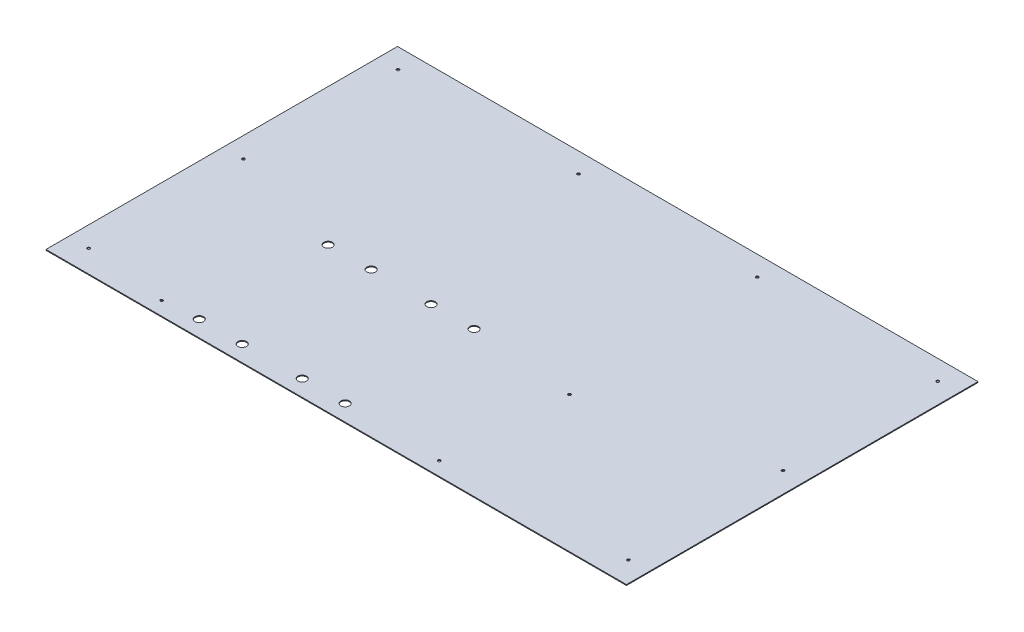
from build123d import *

# Parameters (mm, degrees)
CROQUIS1_W              = 675.4
CROQUIS1_H              = 409
SALIENTE_EXTRUIR1_DEPTH = 1
CORTAR_EXTRUIR1_REACH   = 3
CROQUIS2_R              = 1.6
CORTAR_EXTRUIR2_REACH   = 3
CROQUIS3_R              = 5
CORTAR_EXTRUIR3_REACH   = 3
CROQUIS4_R              = 1.6


with BuildPart() as part:
    # Croquis1 → Saliente-Extruir1 (new body)
    with BuildSketch(Plane(origin=(0, 0, 0), x_dir=(1, 0, 0), z_dir=(0, 1, 0))):
        Rectangle(CROQUIS1_W, CROQUIS1_H)
    extrude(amount=SALIENTE_EXTRUIR1_DEPTH)

    # Croquis2 → Cortar-Extruir1 (cut, up to next)
    with BuildSketch(Plane.XZ, mode=Mode.PRIVATE) as cortar_extruir1_sk1:
        with Locations((-314, 178.6)):
            Circle(CROQUIS2_R)
    cortar_extruir1_tool1 = extrude(cortar_extruir1_sk1.sketch, amount=-CORTAR_EXTRUIR1_REACH, mode=Mode.PRIVATE) & part.part
    add(cortar_extruir1_tool1.solids().sort_by_distance((-314, 0, 178.6))[0], mode=Mode.SUBTRACT)
    # Croquis2 → Cortar-Extruir1 (cut, up to next)
    with BuildSketch(Plane.XZ, mode=Mode.PRIVATE) as cortar_extruir1_sk2:
        with Locations((-314, -181.4)):
            Circle(CROQUIS2_R)
    cortar_extruir1_tool2 = extrude(cortar_extruir1_sk2.sketch, amount=-CORTAR_EXTRUIR1_REACH, mode=Mode.PRIVATE) & part.part
    add(cortar_extruir1_tool2.solids().sort_by_distance((-314, 0, -181.4))[0], mode=Mode.SUBTRACT)
    # Croquis2 → Cortar-Extruir1 (cut, up to next)
    with BuildSketch(Plane.XZ, mode=Mode.PRIVATE) as cortar_extruir1_sk3:
        with Locations((314, -181.4)):
            Circle(CROQUIS2_R)
    cortar_extruir1_tool3 = extrude(cortar_extruir1_sk3.sketch, amount=-CORTAR_EXTRUIR1_REACH, mode=Mode.PRIVATE) & part.part
    add(cortar_extruir1_tool3.solids().sort_by_distance((314, 0, -181.4))[0], mode=Mode.SUBTRACT)
    # Croquis2 → Cortar-Extruir1 (cut, up to next)
    with BuildSketch(Plane.XZ, mode=Mode.PRIVATE) as cortar_extruir1_sk4:
        with Locations((314, 178.6)):
            Circle(CROQUIS2_R)
    cortar_extruir1_tool4 = extrude(cortar_extruir1_sk4.sketch, amount=-CORTAR_EXTRUIR1_REACH, mode=Mode.PRIVATE) & part.part
    add(cortar_extruir1_tool4.solids().sort_by_distance((314, 0, 178.6))[0], mode=Mode.SUBTRACT)
    # Croquis2 → Cortar-Extruir1 (cut, up to next)
    with BuildSketch(Plane.XZ, mode=Mode.PRIVATE) as cortar_extruir1_sk5:
        with Locations((113, 46.25)):
            Circle(CROQUIS2_R)
    cortar_extruir1_tool5 = extrude(cortar_extruir1_sk5.sketch, amount=-CORTAR_EXTRUIR1_REACH, mode=Mode.PRIVATE) & part.part
    add(cortar_extruir1_tool5.solids().sort_by_distance((113, 0, 46.25))[0], mode=Mode.SUBTRACT)

    # Croquis3 → Cortar-Extruir2 (cut, up to next)
    with BuildSketch(Plane.XZ, mode=Mode.PRIVATE) as cortar_extruir2_sk1:
        with Locations((-58.5, 35.6)):
            Circle(CROQUIS3_R)
    cortar_extruir2_tool1 = extrude(cortar_extruir2_sk1.sketch, amount=-CORTAR_EXTRUIR2_REACH, mode=Mode.PRIVATE) & part.part
    add(cortar_extruir2_tool1.solids().sort_by_distance((-58.5, 0, 35.6))[0], mode=Mode.SUBTRACT)
    # Croquis3 → Cortar-Extruir2 (cut, up to next)
    with BuildSketch(Plane.XZ, mode=Mode.PRIVATE) as cortar_extruir2_sk2:
        with Locations((-8.5, 35.6)):
            Circle(CROQUIS3_R)
    cortar_extruir2_tool2 = extrude(cortar_extruir2_sk2.sketch, amount=-CORTAR_EXTRUIR2_REACH, mode=Mode.PRIVATE) & part.part
    add(cortar_extruir2_tool2.solids().sort_by_distance((-8.5, 0, 35.6))[0], mode=Mode.SUBTRACT)
    # Croquis3 → Cortar-Extruir2 (cut, up to next)
    with BuildSketch(Plane.XZ, mode=Mode.PRIVATE) as cortar_extruir2_sk3:
        with Locations((-8.5, 185.6)):
            Circle(CROQUIS3_R)
    cortar_extruir2_tool3 = extrude(cortar_extruir2_sk3.sketch, amount=-CORTAR_EXTRUIR2_REACH, mode=Mode.PRIVATE) & part.part
    add(cortar_extruir2_tool3.solids().sort_by_distance((-8.5, 0, 185.6))[0], mode=Mode.SUBTRACT)
    # Croquis3 → Cortar-Extruir2 (cut, up to next)
    with BuildSketch(Plane.XZ, mode=Mode.PRIVATE) as cortar_extruir2_sk4:
        with Locations((-58.5, 185.6)):
            Circle(CROQUIS3_R)
    cortar_extruir2_tool4 = extrude(cortar_extruir2_sk4.sketch, amount=-CORTAR_EXTRUIR2_REACH, mode=Mode.PRIVATE) & part.part
    add(cortar_extruir2_tool4.solids().sort_by_distance((-58.5, 0, 185.6))[0], mode=Mode.SUBTRACT)
    # Croquis3 → Cortar-Extruir2 (cut, up to next)
    with BuildSketch(Plane.XZ, mode=Mode.PRIVATE) as cortar_extruir2_sk5:
        with Locations((-128.3, 185.6)):
            Circle(CROQUIS3_R)
    cortar_extruir2_tool5 = extrude(cortar_extruir2_sk5.sketch, amount=-CORTAR_EXTRUIR2_REACH, mode=Mode.PRIVATE) & part.part
    add(cortar_extruir2_tool5.solids().sort_by_distance((-128.3, 0, 185.6))[0], mode=Mode.SUBTRACT)
    # Croquis3 → Cortar-Extruir2 (cut, up to next)
    with BuildSketch(Plane.XZ, mode=Mode.PRIVATE) as cortar_extruir2_sk6:
        with Locations((-178.3, 185.6)):
            Circle(CROQUIS3_R)
    cortar_extruir2_tool6 = extrude(cortar_extruir2_sk6.sketch, amount=-CORTAR_EXTRUIR2_REACH, mode=Mode.PRIVATE) & part.part
    add(cortar_extruir2_tool6.solids().sort_by_distance((-178.3, 0, 185.6))[0], mode=Mode.SUBTRACT)
    # Croquis3 → Cortar-Extruir2 (cut, up to next)
    with BuildSketch(Plane.XZ, mode=Mode.PRIVATE) as cortar_extruir2_sk7:
        with Locations((-178.3, 35.6)):
            Circle(CROQUIS3_R)
    cortar_extruir2_tool7 = extrude(cortar_extruir2_sk7.sketch, amount=-CORTAR_EXTRUIR2_REACH, mode=Mode.PRIVATE) & part.part
    add(cortar_extruir2_tool7.solids().sort_by_distance((-178.3, 0, 35.6))[0], mode=Mode.SUBTRACT)
    # Croquis3 → Cortar-Extruir2 (cut, up to next)
    with BuildSketch(Plane.XZ, mode=Mode.PRIVATE) as cortar_extruir2_sk8:
        with Locations((-128.3, 35.6)):
            Circle(CROQUIS3_R)
    cortar_extruir2_tool8 = extrude(cortar_extruir2_sk8.sketch, amount=-CORTAR_EXTRUIR2_REACH, mode=Mode.PRIVATE) & part.part
    add(cortar_extruir2_tool8.solids().sort_by_distance((-128.3, 0, 35.6))[0], mode=Mode.SUBTRACT)

    # Croquis4 → Cortar-Extruir3 (cut, up to next)
    with BuildSketch(Plane.XZ, mode=Mode.PRIVATE) as cortar_extruir3_sk1:
        with Locations((-314, -1.4)):
            Circle(CROQUIS4_R)
    cortar_extruir3_tool1 = extrude(cortar_extruir3_sk1.sketch, amount=-CORTAR_EXTRUIR3_REACH, mode=Mode.PRIVATE) & part.part
    add(cortar_extruir3_tool1.solids().sort_by_distance((-314, 0, -1.4))[0], mode=Mode.SUBTRACT)
    # Croquis4 → Cortar-Extruir3 (cut, up to next)
    with BuildSketch(Plane.XZ, mode=Mode.PRIVATE) as cortar_extruir3_sk2:
        with Locations((314, -1.4)):
            Circle(CROQUIS4_R)
    cortar_extruir3_tool2 = extrude(cortar_extruir3_sk2.sketch, amount=-CORTAR_EXTRUIR3_REACH, mode=Mode.PRIVATE) & part.part
    add(cortar_extruir3_tool2.solids().sort_by_distance((314, 0, -1.4))[0], mode=Mode.SUBTRACT)
    # Croquis4 → Cortar-Extruir3 (cut, up to next)
    with BuildSketch(Plane.XZ, mode=Mode.PRIVATE) as cortar_extruir3_sk3:
        with Locations((-219, 188.6)):
            Circle(CROQUIS4_R)
    cortar_extruir3_tool3 = extrude(cortar_extruir3_sk3.sketch, amount=-CORTAR_EXTRUIR3_REACH, mode=Mode.PRIVATE) & part.part
    add(cortar_extruir3_tool3.solids().sort_by_distance((-219, 0, 188.6))[0], mode=Mode.SUBTRACT)
    # Croquis4 → Cortar-Extruir3 (cut, up to next)
    with BuildSketch(Plane.XZ, mode=Mode.PRIVATE) as cortar_extruir3_sk4:
        with Locations((104, -181.4)):
            Circle(CROQUIS4_R)
    cortar_extruir3_tool4 = extrude(cortar_extruir3_sk4.sketch, amount=-CORTAR_EXTRUIR3_REACH, mode=Mode.PRIVATE) & part.part
    add(cortar_extruir3_tool4.solids().sort_by_distance((104, 0, -181.4))[0], mode=Mode.SUBTRACT)
    # Croquis4 → Cortar-Extruir3 (cut, up to next)
    with BuildSketch(Plane.XZ, mode=Mode.PRIVATE) as cortar_extruir3_sk5:
        with Locations((104, 188.6)):
            Circle(CROQUIS4_R)
    cortar_extruir3_tool5 = extrude(cortar_extruir3_sk5.sketch, amount=-CORTAR_EXTRUIR3_REACH, mode=Mode.PRIVATE) & part.part
    add(cortar_extruir3_tool5.solids().sort_by_distance((104, 0, 188.6))[0], mode=Mode.SUBTRACT)
    # Croquis4 → Cortar-Extruir3 (cut, up to next)
    with BuildSketch(Plane.XZ, mode=Mode.PRIVATE) as cortar_extruir3_sk6:
        with Locations((-104, -181.4)):
            Circle(CROQUIS4_R)
    cortar_extruir3_tool6 = extrude(cortar_extruir3_sk6.sketch, amount=-CORTAR_EXTRUIR3_REACH, mode=Mode.PRIVATE) & part.part
    add(cortar_extruir3_tool6.solids().sort_by_distance((-104, 0, -181.4))[0], mode=Mode.SUBTRACT)


solid = part.part
